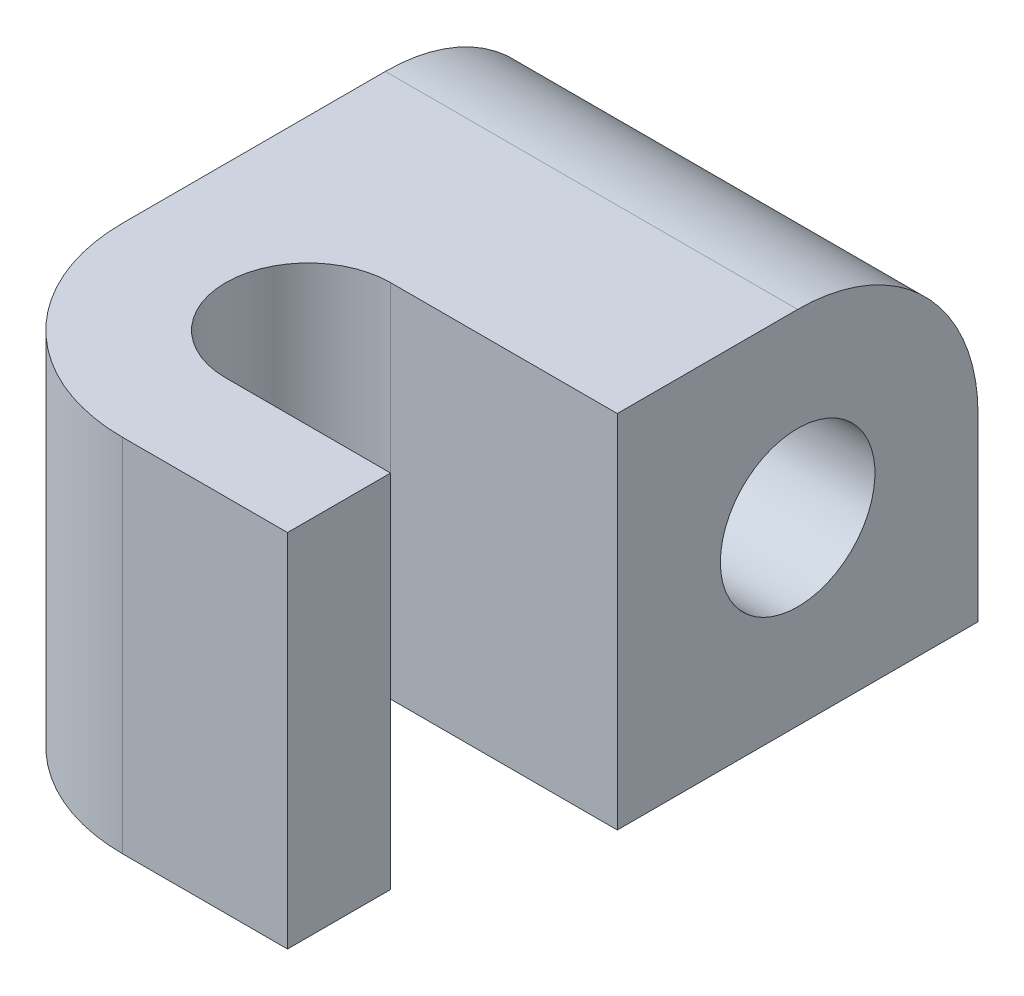
from build123d import *

# Parameters (mm, degrees)
BOSS_EXTRUDE1_DEPTH = 20
BOSS_EXTRUDE2_DEPTH = 17.5
SKETCH3_R           = 3.75
CUT_EXTRUDE1_DEPTH  = 21


with BuildPart() as part:
    # Sketch1 → Boss-Extrude1 (new body)
    with BuildSketch(Plane(origin=(0, 0, 0), x_dir=(0, 0, -1), z_dir=(1, 0, 0))):
        with BuildLine():
            Line((-8.75, 0), (8.75, 0))
            Line((8.75, 0), (8.75, 8.75))
            ThreePointArc((8.75, 8.75), (0, 17.5), (-8.75, 8.75))
            Line((-8.75, 8.75), (-8.75, 0))
        make_face()
    extrude(amount=BOSS_EXTRUDE1_DEPTH)

    # Sketch2 → Boss-Extrude2 (add)
    with BuildSketch(Plane.XZ):
        with BuildLine():
            Line((0, 12.75), (0, 8.75))
            Line((0, 8.75), (0, 0))
            Line((0, 0), (20, 0))
            Line((20, 0), (20, 8.75))
            Line((20, 8.75), (9, 8.75))
            ThreePointArc((9, 8.75), (5, 12.75), (9, 16.75))
            Line((9, 16.75), (17, 16.75))
            Line((17, 16.75), (17, 21.75))
            Line((17, 21.75), (9, 21.75))
            ThreePointArc((9, 21.75), (2.636038969, 19.113961031), (0, 12.75))
        make_face()
    extrude(amount=-BOSS_EXTRUDE2_DEPTH)

    # Sketch3 → Cut-Extrude1 (cut, through all)
    with BuildSketch(Plane.ZY):
        with Locations((0, 8.75)):
            Circle(SKETCH3_R)
    extrude(amount=-CUT_EXTRUDE1_DEPTH, mode=Mode.SUBTRACT)


solid = part.part
